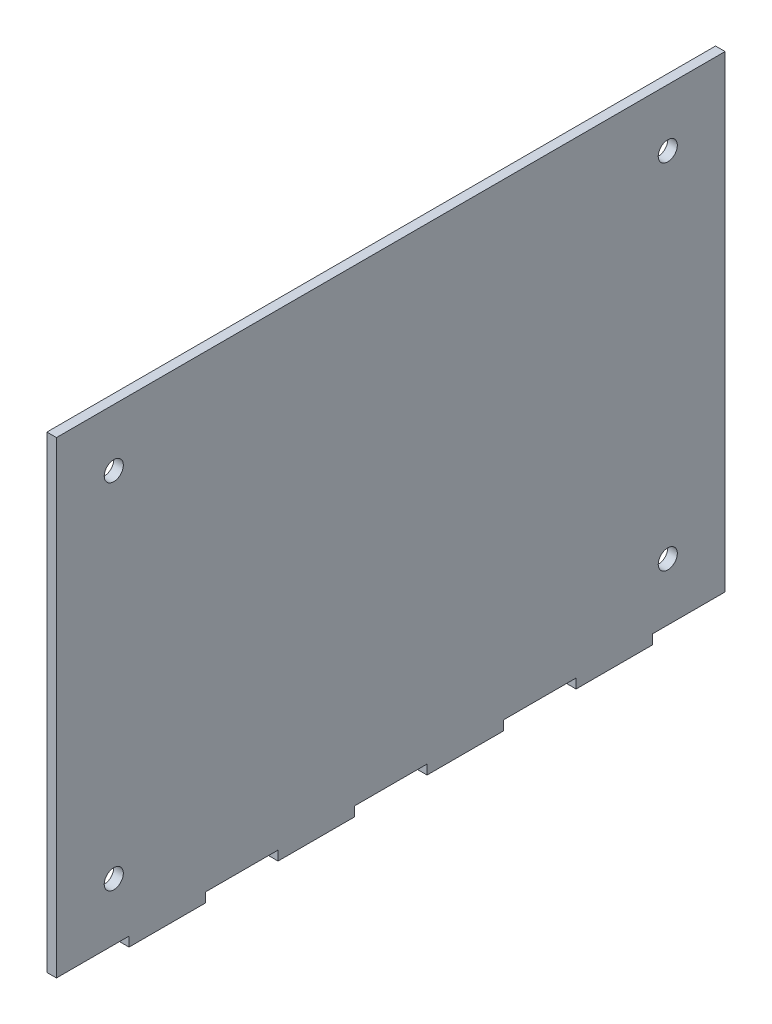
from build123d import *

# Parameters (mm, degrees)
SKIZZE1_W                  = 350
SKIZZE1_H                  = 250
GRUNDPLATTE_DEPTH          = 5
SKIZZE2_W                  = 38
SKIZZE2_H                  = 5
ZAPFEN_BODEN_DEPTH         = 6
SKIZZE3_R                  = 5
VERBINDUNGSBOHRUNGEN_DEPTH = 6


with BuildPart() as part:
    # Skizze1 → Grundplatte (new body)
    with BuildSketch(Plane(origin=(0, 0, 0), x_dir=(0, 0, -1), z_dir=(1, 0, 0))):
        with Locations((0, 125)):
            Rectangle(SKIZZE1_W, SKIZZE1_H)
    extrude(amount=GRUNDPLATTE_DEPTH)

    # Skizze2 → Zapfen Boden (cut, through all)
    with BuildSketch(Plane(origin=(5, 0, 0), x_dir=(0, 0, -1), z_dir=(1, 0, 0))):
        with Locations((-156, 2.5)):
            Rectangle(SKIZZE2_W, SKIZZE2_H)
        with Locations((-78, 2.5)):
            Rectangle(SKIZZE2_W, SKIZZE2_H)
        with Locations((0, 2.5)):
            Rectangle(SKIZZE2_W, SKIZZE2_H)
        with Locations((78, 2.5)):
            Rectangle(SKIZZE2_W, SKIZZE2_H)
        with Locations((156, 2.5)):
            Rectangle(SKIZZE2_W, SKIZZE2_H)
    extrude(amount=-ZAPFEN_BODEN_DEPTH, mode=Mode.SUBTRACT)

    # Skizze3 → Verbindungsbohrungen (cut, through all)
    with BuildSketch(Plane(origin=(5, 0, 0), x_dir=(0, 0, -1), z_dir=(1, 0, 0))):
        with Locations((145, 220)):
            Circle(SKIZZE3_R)
        with Locations((-145, 220)):
            Circle(SKIZZE3_R)
        with Locations((-145, 35)):
            Circle(SKIZZE3_R)
        with Locations((145, 35)):
            Circle(SKIZZE3_R)
    extrude(amount=-VERBINDUNGSBOHRUNGEN_DEPTH, mode=Mode.SUBTRACT)


solid = part.part
